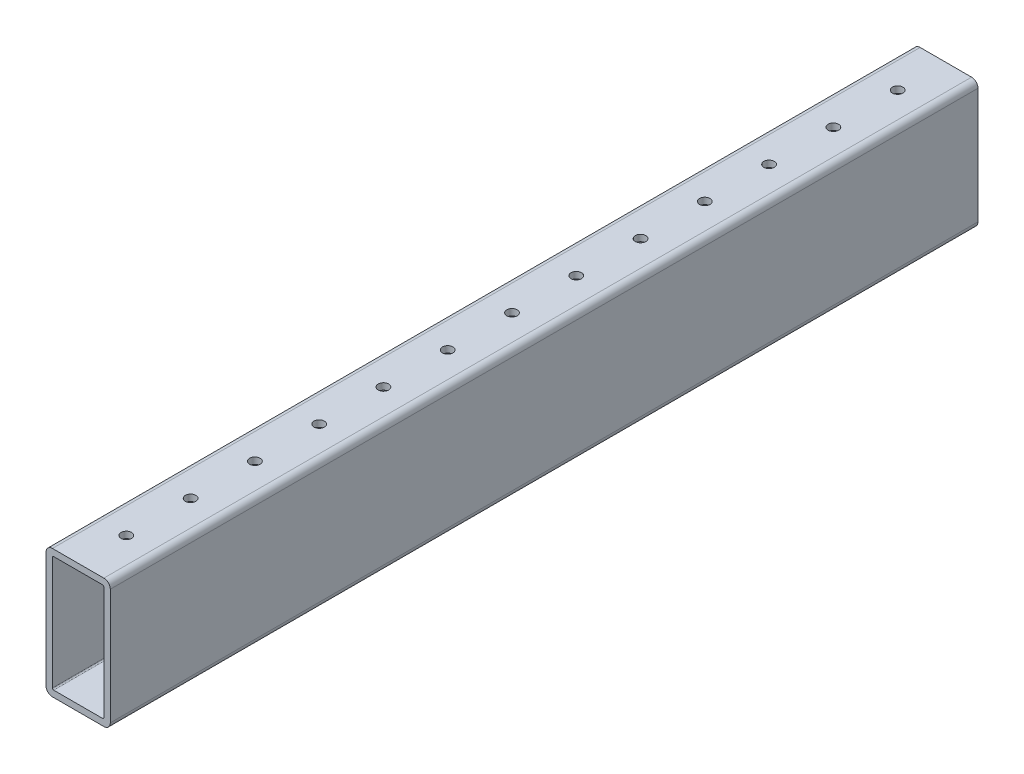
from build123d import *

# Parameters (mm, degrees)
SKETCH1_W                 = 342.9
SKETCH1_H                 = 50.8
BOSS_EXTRUDE1_DEPTH       = 25.4
SKETCH2_W                 = 20.32
SKETCH2_H                 = 45.72
CUT_EXTRUDE1_DEPTH        = 343.9
F_6_CLEARANCE_HOLE1_D     = 4.1402
F_6_CLEARANCE_HOLE1_DEPTH = 50.8
F_6_CLEARANCE_HOLE2_D     = 4.1402
F_6_CLEARANCE_HOLE2_DEPTH = 50.8
FILLET1_R                 = 0.5
FILLET2_R                 = 2.54


with BuildPart() as part:
    # Sketch1 → Boss-Extrude1 (new body)
    with BuildSketch(Plane(origin=(12.7, 0, 0), x_dir=(0, 0, -1), z_dir=(1, 0, 0))):
        Rectangle(SKETCH1_W, SKETCH1_H)
    extrude(amount=-BOSS_EXTRUDE1_DEPTH)

    # Sketch2 → Cut-Extrude1 (cut, through all)
    with BuildSketch(Plane(origin=(0, 0, -171.45), x_dir=(-1, 0, 0), z_dir=(0, 0, -1))):
        Rectangle(SKETCH2_W, SKETCH2_H)
    extrude(amount=-CUT_EXTRUDE1_DEPTH, mode=Mode.SUBTRACT)

    # #6 Clearance Hole1
    with Locations(Plane(origin=(0, -25.4, 0), x_dir=(-1, 0, 0), z_dir=(0, -1, 0))):
        with Locations((0, 711.2), (0, 736.6), (0, 685.8), (0, 660.4), (0, 635), (0, 609.6), (0, 584.2), (0, 558.8), (0, 533.4), (0, 508), (0, 482.6), (0, 457.2), (0, 431.8), (0, 406.4), (0, 381), (0, 355.6), (0, 330.2), (0, 304.8), (0, 279.4), (0, 254), (0, 228.6), (0, 203.2), (0, 177.8), (0, 152.4), (0, 127), (0, 101.6), (0, 76.2), (0, 50.8), (0, 25.4), (0, 0), (0, -25.4), (0, -50.8), (0, -76.2), (0, -101.6), (0, -127), (0, -152.4), (0, -177.8), (0, -203.2), (0, -228.6), (0, -254), (0, -279.4), (0, -304.8), (0, -330.2), (0, -355.6), (0, -381), (0, -406.4), (0, -431.8), (0, -457.2), (0, -482.6), (0, -508), (0, -533.4), (0, -558.8), (0, -584.2), (0, -609.6), (0, -635), (0, -660.4), (0, -685.8), (0, -711.2), (0, -736.6)):
            Hole(F_6_CLEARANCE_HOLE1_D / 2, depth=F_6_CLEARANCE_HOLE1_DEPTH)

    # #6 Clearance Hole2
    with Locations(Plane(origin=(0, 25.4, 0), x_dir=(1, 0, 0), z_dir=(0, 1, 0))):
        with Locations((0, 711.2), (0, 736.6), (0, 685.8), (0, 660.4), (0, 635), (0, 609.6), (0, 584.2), (0, 558.8), (0, 533.4), (0, 508), (0, 482.6), (0, 457.2), (0, 431.8), (0, 406.4), (0, 381), (0, 355.6), (0, 330.2), (0, 304.8), (0, 279.4), (0, 254), (0, 228.6), (0, 203.2), (0, 177.8), (0, 152.4), (0, 127), (0, 101.6), (0, 76.2), (0, 50.8), (0, 25.4), (0, 0), (0, -25.4), (0, -50.8), (0, -76.2), (0, -101.6), (0, -127), (0, -152.4), (0, -177.8), (0, -203.2), (0, -228.6), (0, -254), (0, -279.4), (0, -304.8), (0, -330.2), (0, -355.6), (0, -381), (0, -406.4), (0, -431.8), (0, -457.2), (0, -482.6), (0, -508), (0, -533.4), (0, -558.8), (0, -584.2), (0, -609.6), (0, -635), (0, -660.4), (0, -685.8), (0, -711.2), (0, -736.6)):
            Hole(F_6_CLEARANCE_HOLE2_D / 2, depth=F_6_CLEARANCE_HOLE2_DEPTH)

    # Fillet1
    fillet1_edges = [part.edges().sort_by_distance(p)[0] for p in [
        (-10.16, -22.86, 0),
        (10.16, -22.86, 0),
        (10.16, 22.86, 0),
        (-10.16, 22.86, 0),
    ]]
    fillet(fillet1_edges, radius=FILLET1_R)

    # Fillet2
    fillet2_edges = [part.edges().sort_by_distance(p)[0] for p in [
        (-12.7, 25.4, 0),
        (-12.7, -25.4, 0),
        (12.7, 25.4, 0),
        (12.7, -25.4, 0),
    ]]
    fillet(fillet2_edges, radius=FILLET2_R)


solid = part.part
